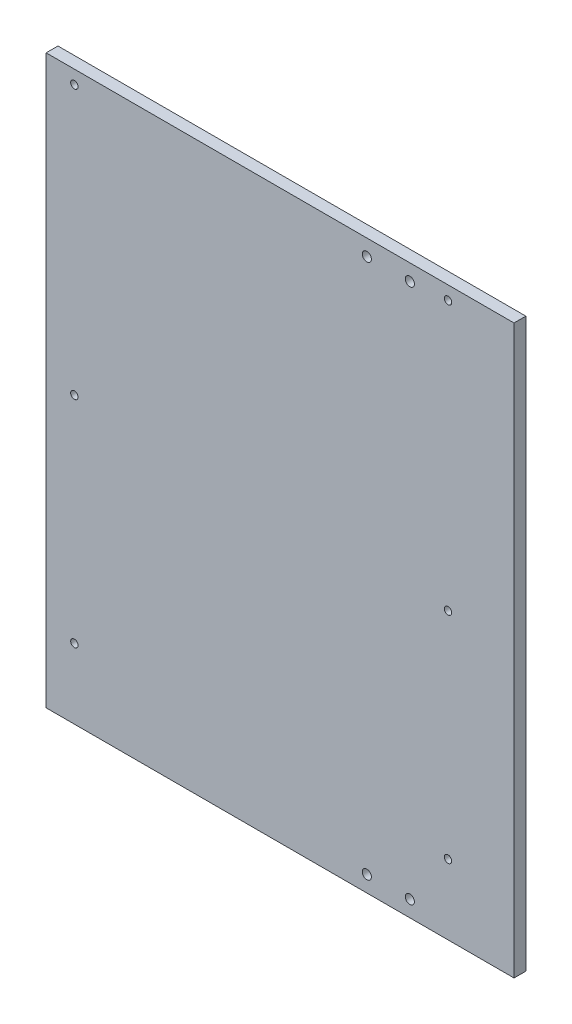
from build123d import *

# Parameters (mm, degrees)
SKETCH1_W               = 174.064160833
SKETCH1_H               = 211.04739762
BOSS_EXTRUDE1_DEPTH     = 4.4
TAP_DRILL_FOR_M3_TAP1_D = 2.75
M3_CLEARANCE_HOLE1_D    = 3.4


with BuildPart() as part:
    # Sketch1 → Boss-Extrude1 (new body)
    with BuildSketch(Plane.XY):
        with Locations((-42.234880602, -320.561484724)):
            Rectangle(SKETCH1_W, SKETCH1_H)
    extrude(amount=BOSS_EXTRUDE1_DEPTH)

    # Tap Drill for M3 Tap1 (through all)
    with Locations(Plane.XY.offset(4.4)):
        with Locations((-118.766961018, -220.037785914), (20.233038982, -220.037785914), (-118.766961018, -320.037785914), (20.233038982, -320.037785914), (20.233038982, -400.037785914), (-118.766961018, -400.037785914)):
            Hole(TAP_DRILL_FOR_M3_TAP1_D / 2)

    # M3 Clearance Hole1 (through all)
    with Locations(Plane.XY.offset(4.4)):
        with Locations((-9.96740718, -420.085183534), (6.04019282, -420.085183534), (-9.96740718, -221.037785914), (6.04019282, -221.037785914)):
            Hole(M3_CLEARANCE_HOLE1_D / 2)


solid = part.part
